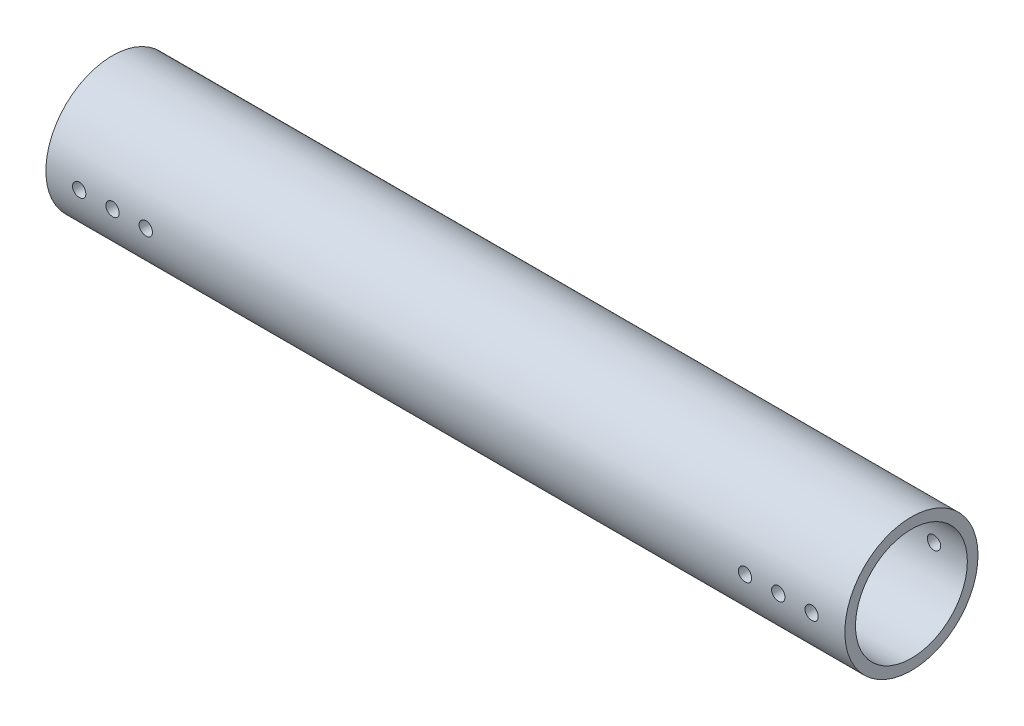
from build123d import *

# Parameters (mm, degrees)
SKETCH_2_R               = 25
SKETCH_2_R_2             = 21
EXTRUDE_2_DEPTH          = 300
CUT_EXTRUDE_2_DEPTH      = 10
CUT_EXTRUDE_2_DEPTH_BACK = 306.163890393
SKETCH_4_R               = 2.5


with BuildPart() as part:
    # Эскиз2 → Бобышка-Вытянуть2 (new body)
    with BuildSketch(Plane(origin=(0, 0, 0), x_dir=(0, 0, -1), z_dir=(1, 0, 0))):
        Circle(SKETCH_2_R)
        Circle(SKETCH_2_R_2, mode=Mode.SUBTRACT)
    extrude(amount=EXTRUDE_2_DEPTH)

    # Эскиз4 → Вырез-Вытянуть2 (cut, two sides: drawn at the far end of the back side and taken through both)
    with BuildSketch(Plane.XY.offset(25).offset(-CUT_EXTRUDE_2_DEPTH_BACK)):
        with Locations((12.5, 0)):
            Circle(SKETCH_4_R)
        with Locations((287.5, 0)):
            Circle(SKETCH_4_R)
        with Locations((25, 0)):
            Circle(SKETCH_4_R)
        with Locations((37.5, 0)):
            Circle(SKETCH_4_R)
        with Locations((275, 0)):
            Circle(SKETCH_4_R)
        with Locations((262.5, 0)):
            Circle(SKETCH_4_R)
    extrude(amount=CUT_EXTRUDE_2_DEPTH + CUT_EXTRUDE_2_DEPTH_BACK, mode=Mode.SUBTRACT)


solid = part.part
